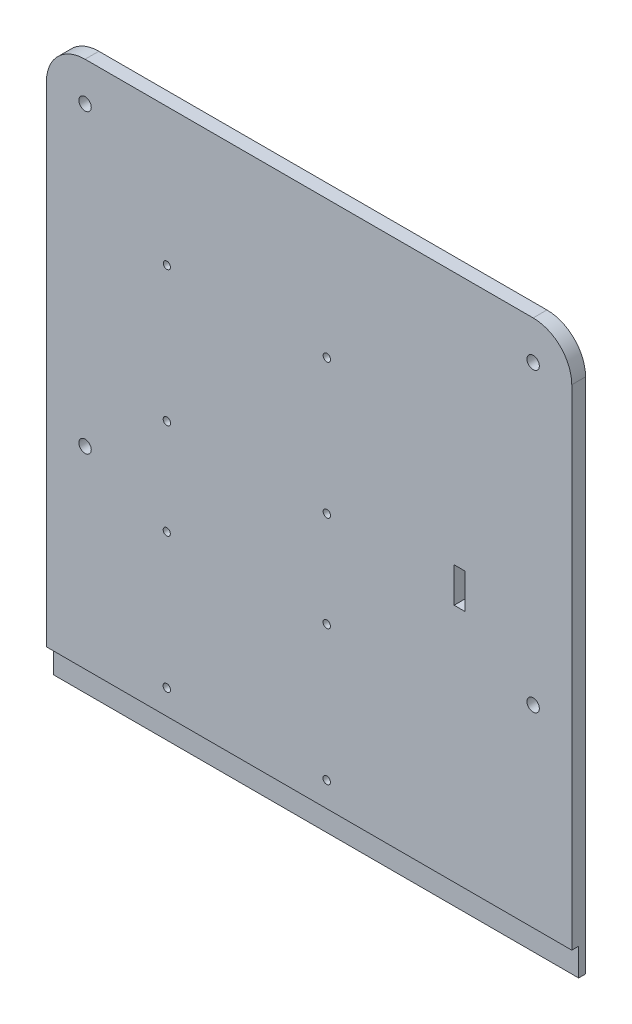
from build123d import *

# Parameters (mm, degrees)
SKETCH4_R           = 2.25
SKETCH4_R_2         = 7.9375
BOSS_EXTRUDE1_DEPTH = 5
CUT_EXTRUDE1_DEPTH  = 191.5
SKETCH8_R           = 1.35
SKETCH8_R_2         = 1.3
CUT_EXTRUDE2_DEPTH  = 6
SKETCH9_R           = 1.35
SKETCH9_R_2         = 1.3
CUT_EXTRUDE3_DEPTH  = 6
CUT_EXTRUDE4_DEPTH  = 2.4
SKETCH12_W          = 4
SKETCH12_H          = 12.7
CUT_EXTRUDE5_DEPTH  = 6


with BuildPart() as part:
    # Sketch4 → Boss-Extrude1 (new body)
    with BuildSketch(Plane.XY):
        with BuildLine():
            Line((-66.080112923, -1201.56262), (96.419887077, -1201.56262))
            ThreePointArc((96.419887077, -1201.56262), (106.319382013, -1197.462114937), (110.419887077, -1187.56262))
            Line((110.419887077, -1187.56262), (110.419887077, -812.43738))
            ThreePointArc((110.419887077, -812.43738), (106.319382013, -802.537885063), (96.419887077, -798.43738))
            Line((96.419887077, -798.43738), (-66.080112923, -798.43738))
            ThreePointArc((-66.080112923, -798.43738), (-75.97960786, -802.537885063), (-80.080112923, -812.43738))
            Line((-80.080112923, -812.43738), (-80.080112923, -1187.56262))
            ThreePointArc((-80.080112923, -1187.56262), (-75.97960786, -1197.462114937), (-66.080112923, -1201.56262))
        make_face()
        with Locations((96.419887077, -1080)):
            Circle(SKETCH4_R, mode=Mode.SUBTRACT)
        with Locations((88.147808187, -1029.0799835)):
            Circle(SKETCH4_R_2, mode=Mode.SUBTRACT)
        with Locations((-66.080112923, -1080)):
            Circle(SKETCH4_R, mode=Mode.SUBTRACT)
        with Locations((96.419887077, -920)):
            Circle(SKETCH4_R, mode=Mode.SUBTRACT)
        with Locations((-66.080112923, -920)):
            Circle(SKETCH4_R, mode=Mode.SUBTRACT)
        with Locations((-66.080112923, -1187.56262)):
            Circle(SKETCH4_R, mode=Mode.SUBTRACT)
        with Locations((96.419887077, -1187.56262)):
            Circle(SKETCH4_R, mode=Mode.SUBTRACT)
        with Locations((-66.080112923, -812.43738)):
            Circle(SKETCH4_R, mode=Mode.SUBTRACT)
        with Locations((96.419887077, -812.43738)):
            Circle(SKETCH4_R, mode=Mode.SUBTRACT)
    extrude(amount=BOSS_EXTRUDE1_DEPTH)

    # Sketch5 → Cut-Extrude1 (cut, through all)
    with BuildSketch(Plane(origin=(110.419887077, 0, 0), x_dir=(0, 0, -1), z_dir=(1, 0, 0))):
        Polygon((-2.5, -990), (-2.5, -1000), (0, -1000), (105.330135386, -1133.485190723), (-31.100407904, -1241.139436993), (-117.784745415, -1052.296655995), (-5, -990), align=None)
    extrude(amount=-CUT_EXTRUDE1_DEPTH, mode=Mode.SUBTRACT)

    # Sketch8 → Cut-Extrude2 (cut, through all)
    with BuildSketch(Plane(origin=(0, 0, 0), x_dir=(1, 0, 0), z_dir=(0, 0, -1))):
        with Locations((-36.405274736, 897.30672742)):
            Circle(SKETCH8_R)
        with Locations((21.594725264, 897.30672742)):
            Circle(SKETCH8_R)
        with Locations((21.594725264, 848.30672742)):
            Circle(SKETCH8_R)
        with Locations((-36.405274736, 848.30672742)):
            Circle(SKETCH8_R_2)
    extrude(amount=-CUT_EXTRUDE2_DEPTH, mode=Mode.SUBTRACT)

    # Sketch9 → Cut-Extrude3 (cut, through all)
    with BuildSketch(Plane(origin=(0, 0, 0), x_dir=(1, 0, 0), z_dir=(0, 0, -1))):
        with Locations((-36.451263927, 981.041793441)):
            Circle(SKETCH9_R)
        with Locations((21.548736073, 981.041793441)):
            Circle(SKETCH9_R)
        with Locations((21.548736073, 932.041793441)):
            Circle(SKETCH9_R)
        with Locations((-36.451263927, 932.041793441)):
            Circle(SKETCH9_R_2)
    extrude(amount=-CUT_EXTRUDE3_DEPTH, mode=Mode.SUBTRACT)

    # Sketch11 → Cut-Extrude4 (cut)
    with BuildSketch(Plane(origin=(0, 0, 0), x_dir=(-1, 0, 0), z_dir=(0, 0, -1))):
        Polygon((-20.122482078, -845.75672742), (-23.066968451, -845.75672742), (-24.539211637, -848.30672742), (-23.066968451, -850.85672742), (-20.122482078, -850.85672742), (-18.650238891, -848.30672742), align=None)
        Polygon((34.933031549, -845.75672742), (33.460788363, -848.30672742), (34.933031549, -850.85672742), (37.877517922, -850.85672742), (39.349761109, -848.30672742), (37.877517922, -845.75672742), align=None)
        Polygon((34.933031549, -894.75672742), (33.460788363, -897.30672742), (34.933031549, -899.85672742), (37.877517922, -899.85672742), (39.349761109, -897.30672742), (37.877517922, -894.75672742), align=None)
        Polygon((-20.122482078, -894.75672742), (-23.066968451, -894.75672742), (-24.539211637, -897.30672742), (-23.066968451, -899.85672742), (-20.122482078, -899.85672742), (-18.650238891, -897.30672742), align=None)
        Polygon((-20.076492886, -929.491793441), (-23.020979259, -929.491793441), (-24.493222445, -932.041793441), (-23.020979259, -934.591793441), (-20.076492886, -934.591793441), (-18.6042497, -932.041793441), align=None)
        Polygon((34.979020741, -929.491793441), (33.506777555, -932.041793441), (34.979020741, -934.591793441), (37.923507114, -934.591793441), (39.3957503, -932.041793441), (37.923507114, -929.491793441), align=None)
        Polygon((-23.020979259, -978.491793441), (-24.493222445, -981.041793441), (-23.020979259, -983.591793441), (-20.076492886, -983.591793441), (-18.6042497, -981.041793441), (-20.076492886, -978.491793441), align=None)
        Polygon((34.979020741, -978.491793441), (33.506777555, -981.041793441), (34.979020741, -983.591793441), (37.923507114, -983.591793441), (39.3957503, -981.041793441), (37.923507114, -978.491793441), align=None)
    extrude(amount=-CUT_EXTRUDE4_DEPTH, mode=Mode.SUBTRACT)

    # Sketch12 → Cut-Extrude5 (cut, through all)
    with BuildSketch(Plane.XY.offset(5)):
        with Locations((69.759334594, -896.65140708)):
            Rectangle(SKETCH12_W, SKETCH12_H)
    extrude(amount=-CUT_EXTRUDE5_DEPTH, mode=Mode.SUBTRACT)


solid = part.part
